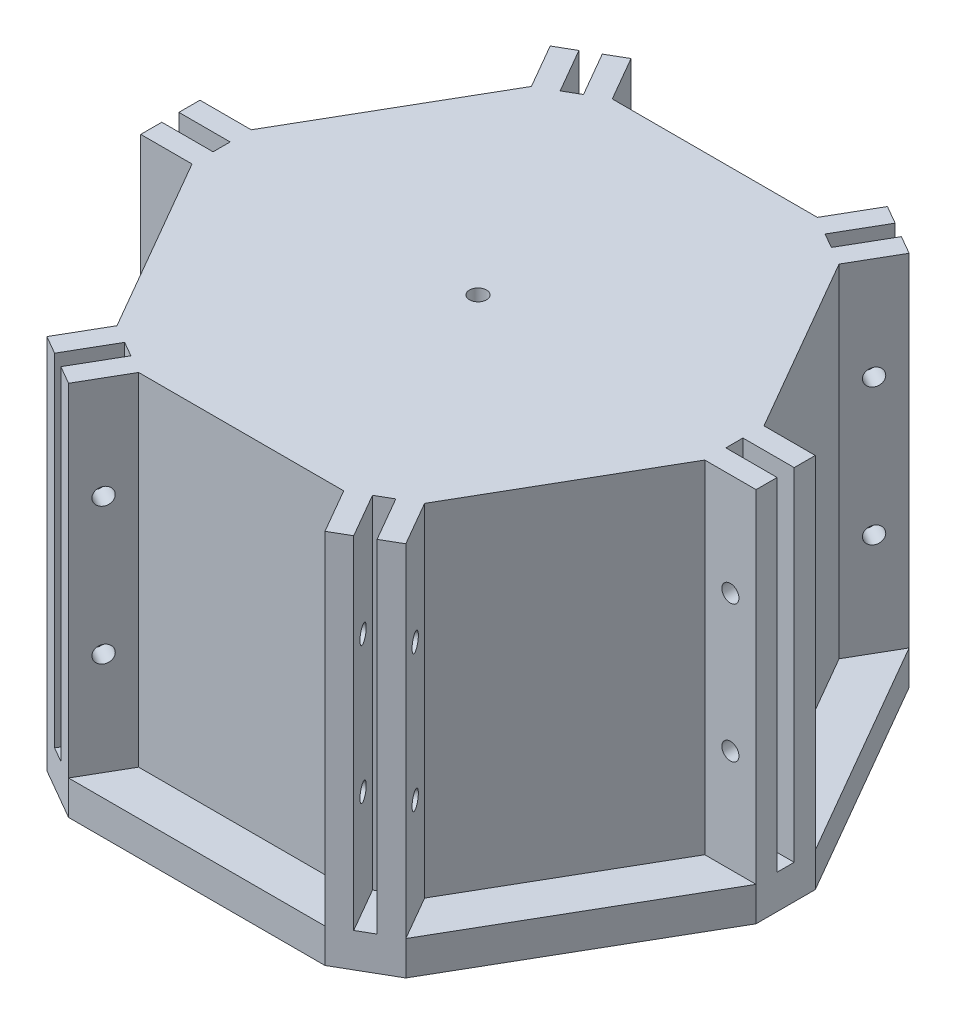
from build123d import *

# Parameters (mm, degrees)
BOSS_EXTRUDE1_DEPTH = 100
BOSS_EXTRUDE2_DEPTH = 100
CIRPATTERN1_COUNT   = 6
SKETCH3_W           = 5
SKETCH3_H           = 100
CUT_EXTRUDE1_DEPTH  = 15
CIRPATTERN2_COUNT   = 6
BOSS_EXTRUDE3_DEPTH = 10
SKETCH5_R           = 2.5
CUT_EXTRUDE2_DEPTH  = 200
SKETCH6_R           = 2.5
CUT_EXTRUDE3_DEPTH  = 163.384361005
CIRPATTERN3_COUNT   = 6
BOSS_EXTRUDE4_DEPTH = 100
CIRPATTERN4_COUNT   = 6
BOSS_EXTRUDE5_DEPTH = 10
SKETCH9_R           = 2.5
CUT_EXTRUDE4_DEPTH  = 165.221585365


with BuildPart() as part:
    # Sketch1 → Boss-Extrude1 (new body)
    with BuildSketch(Plane(origin=(0, 0, 0), x_dir=(1, 0, 0), z_dir=(0, 1, 0))):
        Polygon((70, 0), (35, 60.621778265), (-35, 60.621778265), (-70, 0), (-35, -60.621778265), (35, -60.621778265), align=None)
    extrude(amount=BOSS_EXTRUDE1_DEPTH)

    # Sketch2 → Boss-Extrude2 (add)
    with BuildSketch(Plane(origin=(0, 100, 0), x_dir=(1, 0, 0), z_dir=(0, 1, 0))):
        Polygon((52.499779997, 73.612286341), (37.500220003, 82.272286341), (24.798707265, 60.272620945), (39.798267258, 51.612620945), align=None)
    boss_extrude2 = extrude(amount=-BOSS_EXTRUDE2_DEPTH)

    # CirPattern1: Boss-Extrude2 ×6 about axis
    cirpattern1_axis = Axis((0, -5, 0), (0, 1, 0))
    for i in range(1, CIRPATTERN1_COUNT):
        add(boss_extrude2.rotate(cirpattern1_axis, i * 360 / CIRPATTERN1_COUNT))

    # Sketch3 → Cut-Extrude1 (cut)
    with BuildSketch(Plane(origin=(90, 0, 0), x_dir=(0, 0, -1), z_dir=(1, 0, 0))):
        with Locations((0, 50)):
            Rectangle(SKETCH3_W, SKETCH3_H)
    cut_extrude1 = extrude(amount=-CUT_EXTRUDE1_DEPTH, mode=Mode.SUBTRACT)

    # CirPattern2: Cut-Extrude1 ×6 about axis
    cirpattern2_axis = Axis((0, -5, 0), (0, 1, 0))
    for i in range(1, CIRPATTERN2_COUNT):
        add(cut_extrude1.rotate(cirpattern2_axis, i * 360 / CIRPATTERN2_COUNT), mode=Mode.SUBTRACT)

    # Sketch4 → Boss-Extrude3 (add)
    with BuildSketch(Plane.XZ):
        Polygon((-52.499779997, 73.612286341), (-37.500220003, 82.272286341), (37.500220003, 82.272286341), (52.499779997, 73.612286341), (90, 8.66), (90, -8.66), (52.499779997, -73.612286341), (37.500220003, -82.272286341), (-37.500220003, -82.272286341), (-52.499779997, -73.612286341), (-90, -8.66), (-90, 8.66), align=None)
        Polygon((50, 0), (25, 43.301270189), (-25, 43.301270189), (-50, 0), (-25, -43.301270189), (25, -43.301270189), align=None, mode=Mode.SUBTRACT)
    extrude(amount=BOSS_EXTRUDE3_DEPTH)

    # Sketch5 → Cut-Extrude2 (cut)
    with BuildSketch(Plane(origin=(0, 100, 0), x_dir=(1, 0, 0), z_dir=(0, 1, 0))):
        Circle(SKETCH5_R)
    extrude(amount=-CUT_EXTRUDE2_DEPTH, mode=Mode.SUBTRACT)

    # Sketch6 → Cut-Extrude3 (cut, through all)
    with BuildSketch(Plane.XY.offset(8.66)):
        with Locations((82.5, 70)):
            Circle(SKETCH6_R)
        with Locations((82.5, 30)):
            Circle(SKETCH6_R)
    cut_extrude3 = extrude(amount=-CUT_EXTRUDE3_DEPTH, mode=Mode.SUBTRACT)

    # CirPattern3: Cut-Extrude3 ×6 about axis
    cirpattern3_axis = Axis((0, -5, 0), (0, 1, 0))
    for i in range(1, CIRPATTERN3_COUNT):
        add(cut_extrude3.rotate(cirpattern3_axis, i * 360 / CIRPATTERN3_COUNT), mode=Mode.SUBTRACT)

    # Sketch7 → Boss-Extrude4 (add)
    with BuildSketch(Plane(origin=(0, 0, 0), x_dir=(1, 0, 0), z_dir=(0, 1, 0))):
        Polygon((-65.000146669, 8.66), (-39.999853331, 51.961778265), (-44.999706662, 60.621778265), (-74.999853331, 8.66), align=None)
    boss_extrude4 = extrude(amount=BOSS_EXTRUDE4_DEPTH)

    # CirPattern4: Boss-Extrude4 ×6 about axis
    cirpattern4_axis = Axis((0, -5, 0), (0, 1, 0))
    for i in range(1, CIRPATTERN4_COUNT):
        add(boss_extrude4.rotate(cirpattern4_axis, i * 360 / CIRPATTERN4_COUNT))

    # Sketch8 → Boss-Extrude5 (add)
    with BuildSketch(Plane.XZ):
        Polygon((50, 0), (25, 43.301270189), (-25, 43.301270189), (-50, 0), (-25, -43.301270189), (25, -43.301270189), align=None)
    extrude(amount=BOSS_EXTRUDE5_DEPTH)

    # Sketch9 → Cut-Extrude4 (cut, through all)
    with BuildSketch(Plane(origin=(0, 100, 0), x_dir=(1, 0, 0), z_dir=(0, 1, 0))):
        Circle(SKETCH9_R)
    extrude(amount=-CUT_EXTRUDE4_DEPTH, mode=Mode.SUBTRACT)


solid = part.part
